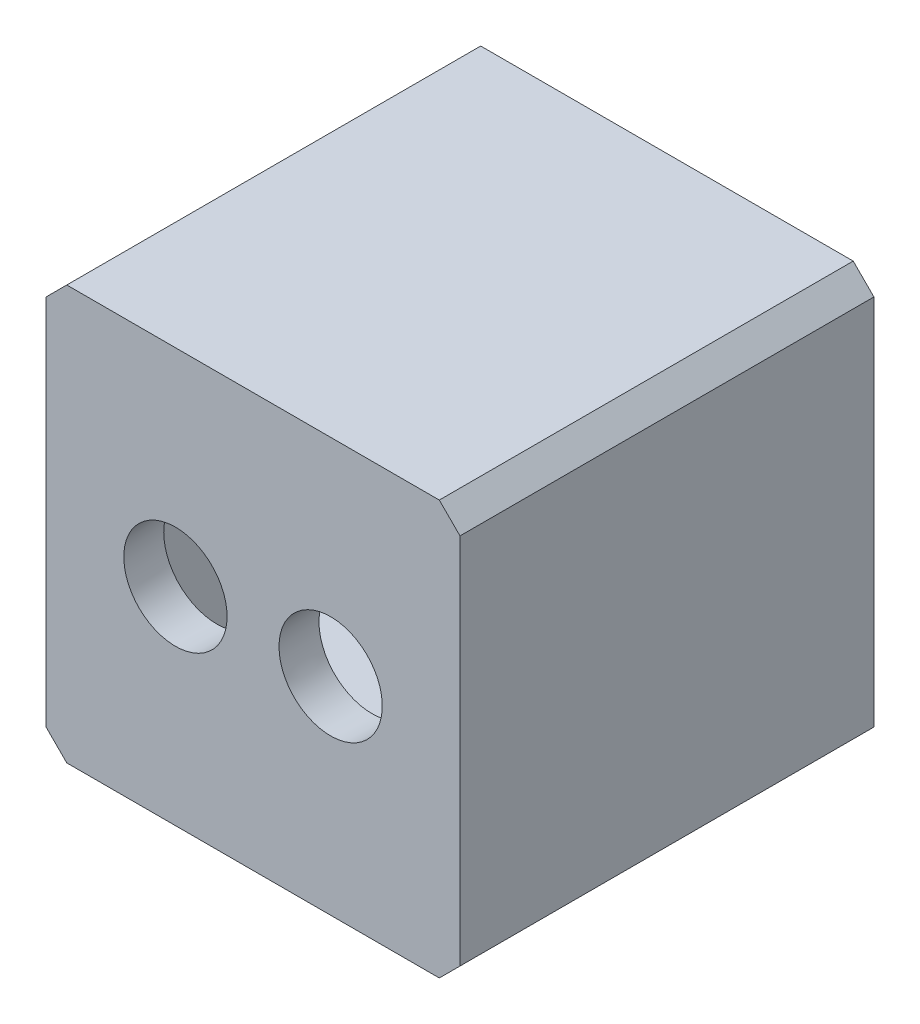
from build123d import *

# Parameters (mm, degrees)
ESQUISSE1_W                       = 20
ESQUISSE1_H                       = 20
BOSS_EXTRU_1_DEPTH                = 20
ENL_V_START                       = -3
ESQUISSE2_R                       = 2.6
ENL_V_MAT_EXTRU_1_DEPTH           = 53.506491459
ENL_V_MAT_EXTRU_1_DRAFT           = 2
ENL_V_MAT_EXTRU_1_PROFILE_2_DEPTH = 53.506491459
ENL_V_MAT_EXTRU_1_PROFILE_2_DRAFT = 2
ESQUISSE3_W                       = 16
ESQUISSE3_H                       = 16
ENL_V_MAT_EXTRU_2_DEPTH           = 18
CHANFREIN1_SIZE                   = 1


with BuildPart() as part:
    # Esquisse1 → Boss.-Extru.1 (new body)
    with BuildSketch(Plane.XY):
        with Locations((-24.630410255, 19.182655502)):
            Rectangle(ESQUISSE1_W, ESQUISSE1_H)
    extrude(amount=BOSS_EXTRU_1_DEPTH)


with BuildPart() as enl_v_mat_extru_1_tool:
    # Esquisse2 → Enlèv. mat.-Extru.1 (with draft: the straight prism first)
    with BuildSketch(Plane.XY.offset(20).offset(ENL_V_START)):
        with Locations((-28.380410255, 19.182655502)):
            Circle(ESQUISSE2_R)
    extrude(amount=ENL_V_MAT_EXTRU_1_DEPTH)
    # Enlèv. mat.-Extru.1: the draft: its side faces are tilted about the plane it starts from
    enl_v_mat_extru_1_sides = [enl_v_mat_extru_1_tool.faces().sort_by_distance(p)[0] for p in [
        (-30.980410255, 19.182655502, 43.75324573),
    ]]
    draft(enl_v_mat_extru_1_sides, Plane.XY.offset(20).offset(ENL_V_START), ENL_V_MAT_EXTRU_1_DRAFT)


with BuildPart() as part_1:
    add(part.part)

    # Enlèv. mat.-Extru.1: cut by enl_v_mat_extru_1_tool
    add(enl_v_mat_extru_1_tool.part, mode=Mode.SUBTRACT)


with BuildPart() as enl_v_mat_extru_1_profile_2_tool:
    # Esquisse2 → Enlèv. mat.-Extru.1 profile 2 (with draft: the straight prism first)
    with BuildSketch(Plane.XY.offset(20).offset(ENL_V_START)):
        with Locations((-20.880410255, 19.182655502)):
            Circle(ESQUISSE2_R)
    extrude(amount=ENL_V_MAT_EXTRU_1_PROFILE_2_DEPTH)
    # Enlèv. mat.-Extru.1 profile 2: the draft: its side faces are tilted about the plane it starts from
    enl_v_mat_extru_1_profile_2_sides = [enl_v_mat_extru_1_profile_2_tool.faces().sort_by_distance(p)[0] for p in [
        (-23.480410255, 19.182655502, 43.75324573),
    ]]
    draft(enl_v_mat_extru_1_profile_2_sides, Plane.XY.offset(20).offset(ENL_V_START), ENL_V_MAT_EXTRU_1_PROFILE_2_DRAFT)


with BuildPart() as part_2:
    add(part_1.part)

    # Enlèv. mat.-Extru.1 profile 2: cut by enl_v_mat_extru_1_profile_2_tool
    add(enl_v_mat_extru_1_profile_2_tool.part, mode=Mode.SUBTRACT)

    # Esquisse3 → Enlèv. mat.-Extru.2 (cut)
    with BuildSketch(Plane(origin=(0, 0, 0), x_dir=(-1, 0, 0), z_dir=(0, 0, -1))):
        with Locations((24.630410255, 19.182655502)):
            Rectangle(ESQUISSE3_W, ESQUISSE3_H)
    extrude(amount=-ENL_V_MAT_EXTRU_2_DEPTH, mode=Mode.SUBTRACT)

    # Chanfrein1
    chanfrein1_edges = [part_2.edges().sort_by_distance(p)[0] for p in [
        (-34.630410255, 29.182655502, 10),
        (-14.630410255, 29.182655502, 10),
        (-14.630410255, 9.182655502, 10),
        (-34.630410255, 9.182655502, 10),
    ]]
    chamfer(chanfrein1_edges, length=CHANFREIN1_SIZE)


solid = part_2.part
